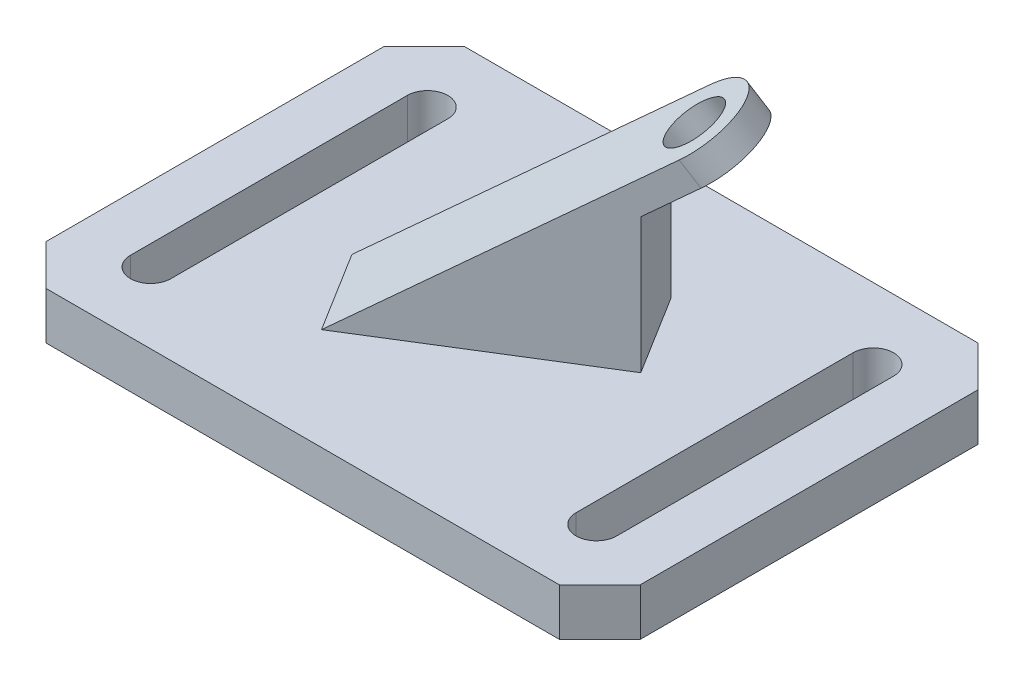
from build123d import *

# Parameters (mm, degrees)
BOSS_EXTRUDE1_DEPTH     = 7
BOSS_EXTRUDE2_DEPTH     = 7
SKETCH4_R               = 4
CUT_EXTRUDE1_DEPTH      = 47.435908473
CUT_EXTRUDE1_DEPTH_BACK = 14


with BuildPart() as part:
    # Sketch1 → Boss-Extrude1 (new body)
    with BuildSketch(Plane(origin=(0, 0, 0), x_dir=(1, 0, 0), z_dir=(0, 1, 0))):
        Polygon((-44, 25), (-38, 31), (38, 31), (44, 25), (44, -25), (38, -31), (-38, -31), (-44, -25), align=None)
        with BuildLine():
            Line((-36, -20.5), (-36, 20.5))
            ThreePointArc((-36, 20.5), (-33, 23.5), (-30, 20.5))
            Line((-30, 20.5), (-30, -20.5))
            ThreePointArc((-30, -20.5), (-33, -23.5), (-36, -20.5))
        make_face(mode=Mode.SUBTRACT)
        with BuildLine():
            Line((36, -20.5), (36, 20.5))
            ThreePointArc((36, 20.5), (33, 23.5), (30, 20.5))
            Line((30, 20.5), (30, -20.5))
            ThreePointArc((30, -20.5), (33, -23.5), (36, -20.5))
        make_face(mode=Mode.SUBTRACT)
    extrude(amount=BOSS_EXTRUDE1_DEPTH)

    # Sketch3 → Boss-Extrude2 (add, symmetric)
    with BuildSketch(Plane(origin=(0, 0, 0), x_dir=(0.849441251, 0, -0.527683201), z_dir=(0.527683201, 0, 0.849441251))):
        Polygon((15.483777963, 7), (-18.849066913, 7), (25.26789187, 39.052846762), (27.619032879, 35.816778784), (15.483777963, 27), align=None)
    extrude(amount=BOSS_EXTRUDE2_DEPTH, both=True)

    # Sketch4 → Cut-Extrude1 (cut, two sides)
    with BuildSketch(Plane(origin=(-8.359258135, 13.544823437, 5.192872478), x_dir=(0.866435488, 0.466201263, 0.178734239), z_dir=(-0.49928904, 0.809016994, 0.310164404))) as cut_extrude1_sk:
        with Locations((28.868116916, 22.166684098)):
            Circle(SKETCH4_R)
        with BuildLine():
            ThreePointArc((24.604923104, 27.718726833), (29.779470735, 29.107104418), (34.420159658, 26.4298779))
            Line((34.420159658, 26.4298779), (30.156965838, 31.981920644))
            Line((30.156965838, 31.981920644), (24.604923104, 27.718726833))
        make_face()
        with BuildLine():
            ThreePointArc((34.420159658, 26.4298779), (35.808537235, 21.255330279), (33.131310727, 16.614641364))
            Line((33.131310727, 16.614641364), (38.683353462, 20.877835176))
            Line((38.683353462, 20.877835176), (34.420159658, 26.4298779))
        make_face()
    extrude(amount=CUT_EXTRUDE1_DEPTH, mode=Mode.SUBTRACT)
    extrude(cut_extrude1_sk.sketch, amount=-CUT_EXTRUDE1_DEPTH_BACK, mode=Mode.SUBTRACT)


solid = part.part
